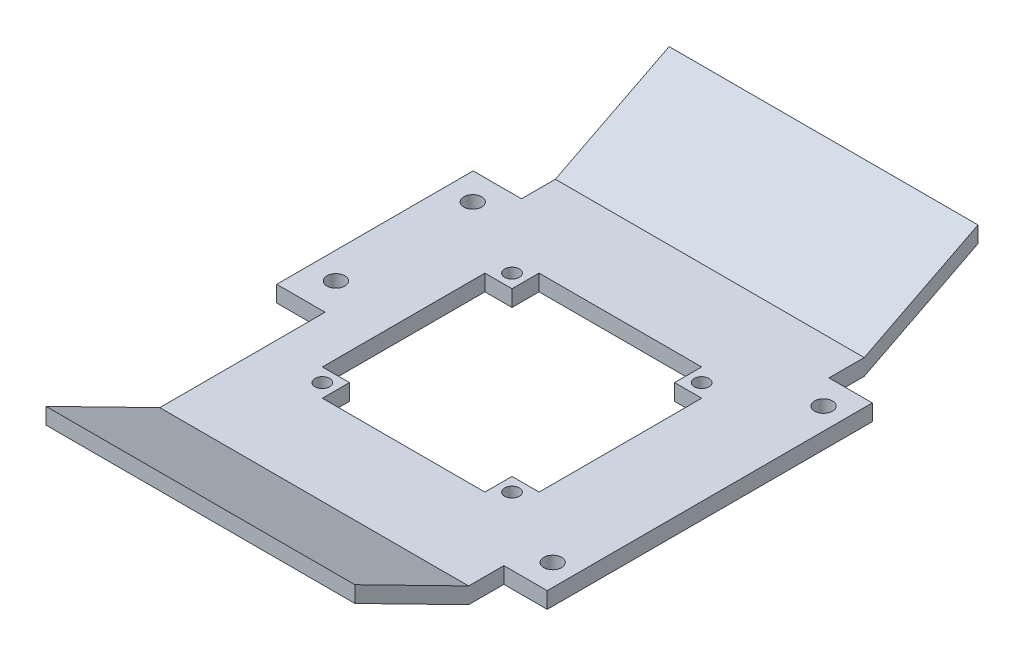
from build123d import *

# Parameters (mm, degrees)
BOSS_EXTRUDE1_DEPTH = 28.5
SKETCH2_R           = 1.35
CUT_EXTRUDE1_DEPTH  = 57
SKETCH3_W           = 8.922387131
SKETCH3_H           = 36.251387657
SKETCH3_R           = 1.65
SKETCH3_W_2         = 8
SKETCH3_H_2         = 60
BOSS_EXTRUDE2_DEPTH = 3


with BuildPart() as part:
    # Sketch1 → Boss-Extrude1 (new body, symmetric)
    with BuildSketch(Plane(origin=(0, 0, 0), x_dir=(0, 0, -1), z_dir=(1, 0, 0))):
        Polygon((-36.5, 0), (36.5, 0), (57.5, 10.700034439), (57.5, 13.700034439), (36.5, 3), (-36.5, 3), (-57.5, 13.700034439), (-57.5, 10.700034439), align=None)
    extrude(amount=BOSS_EXTRUDE1_DEPTH, both=True)

    # Sketch2 → Cut-Extrude1 (cut)
    with BuildSketch(Plane(origin=(0, 0, 0), x_dir=(1, 0, 0), z_dir=(0, 1, 0))):
        with Locations((-17.5, 17.5)):
            Circle(SKETCH2_R)
        with Locations((17.5, 17.5)):
            Circle(SKETCH2_R)
        with Locations((17.5, -17.5)):
            Circle(SKETCH2_R)
        with Locations((-17.5, -17.5)):
            Circle(SKETCH2_R)
        Polygon((-15, 20), (15, 20), (15, 15), (20, 15), (20, -15), (15, -15), (15, -20), (-15, -20), (-15, -15), (-20, -15), (-20, 15), (-15, 15), align=None)
    extrude(amount=CUT_EXTRUDE1_DEPTH, mode=Mode.SUBTRACT)

    # Sketch3 → Boss-Extrude2 (add)
    with BuildSketch(Plane(origin=(0, 0, 0), x_dir=(1, 0, 0), z_dir=(0, 1, 0))):
        with Locations((-32.961193565, 12.125693829)):
            Rectangle(SKETCH3_W, SKETCH3_H)
        with Locations((-32.5, 0)):
            Circle(SKETCH3_R, mode=Mode.SUBTRACT)
        with Locations((-32.5, 25.251387657)):
            Circle(SKETCH3_R, mode=Mode.SUBTRACT)
        with Locations((32.5, 0)):
            Rectangle(SKETCH3_W_2, SKETCH3_H_2)
        with Locations((32.5, -25)):
            Circle(SKETCH3_R, mode=Mode.SUBTRACT)
        with Locations((32.5, 25)):
            Circle(SKETCH3_R, mode=Mode.SUBTRACT)
    extrude(amount=BOSS_EXTRUDE2_DEPTH)


solid = part.part
